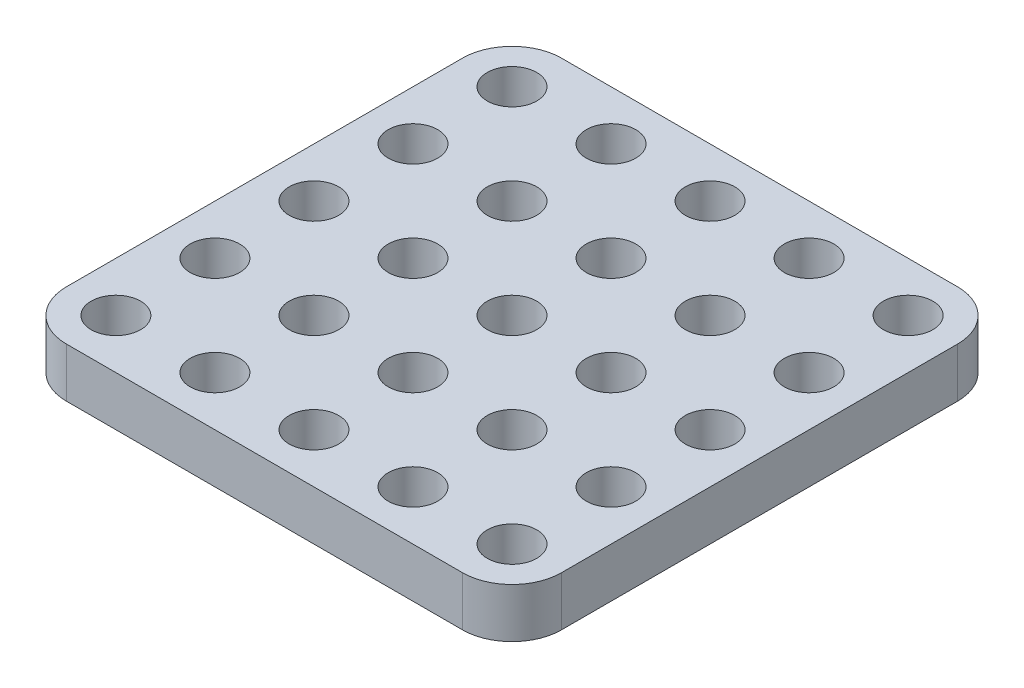
from build123d import *

# Parameters (mm, degrees)
SKETCH1_R           = 2.5
BOSS_EXTRUDE1_DEPTH = 5


with BuildPart() as part:
    # Sketch1 → Boss-Extrude1 (new body)
    with BuildSketch(Plane(origin=(0, 0, 0), x_dir=(1, 0, 0), z_dir=(0, 1, 0))):
        with BuildLine():
            Line((20, -25), (-20, -25))
            ThreePointArc((-20, -25), (-23.535533906, -23.535533906), (-25, -20))
            Line((-25, -20), (-25, 20))
            ThreePointArc((-25, 20), (-23.535533906, 23.535533906), (-20, 25))
            Line((-20, 25), (20, 25))
            ThreePointArc((20, 25), (23.535533906, 23.535533906), (25, 20))
            Line((25, 20), (25, -20))
            ThreePointArc((25, -20), (23.535533906, -23.535533906), (20, -25))
        make_face()
        with Locations((-20, 20)):
            Circle(SKETCH1_R, mode=Mode.SUBTRACT)
        with Locations((-10, 20)):
            Circle(SKETCH1_R, mode=Mode.SUBTRACT)
        with Locations((0, 20)):
            Circle(SKETCH1_R, mode=Mode.SUBTRACT)
        with Locations((10, 20)):
            Circle(SKETCH1_R, mode=Mode.SUBTRACT)
        with Locations((20, 20)):
            Circle(SKETCH1_R, mode=Mode.SUBTRACT)
        with Locations((-10, 10)):
            Circle(SKETCH1_R, mode=Mode.SUBTRACT)
        with Locations((0, 10)):
            Circle(SKETCH1_R, mode=Mode.SUBTRACT)
        with Locations((10, 10)):
            Circle(SKETCH1_R, mode=Mode.SUBTRACT)
        with Locations((20, 10)):
            Circle(SKETCH1_R, mode=Mode.SUBTRACT)
        with Locations((-10, 0)):
            Circle(SKETCH1_R, mode=Mode.SUBTRACT)
        Circle(SKETCH1_R, mode=Mode.SUBTRACT)
        with Locations((10, 0)):
            Circle(SKETCH1_R, mode=Mode.SUBTRACT)
        with Locations((20, 0)):
            Circle(SKETCH1_R, mode=Mode.SUBTRACT)
        with Locations((-10, -10)):
            Circle(SKETCH1_R, mode=Mode.SUBTRACT)
        with Locations((0, -10)):
            Circle(SKETCH1_R, mode=Mode.SUBTRACT)
        with Locations((10, -10)):
            Circle(SKETCH1_R, mode=Mode.SUBTRACT)
        with Locations((20, -10)):
            Circle(SKETCH1_R, mode=Mode.SUBTRACT)
        with Locations((-10, -20)):
            Circle(SKETCH1_R, mode=Mode.SUBTRACT)
        with Locations((0, -20)):
            Circle(SKETCH1_R, mode=Mode.SUBTRACT)
        with Locations((10, -20)):
            Circle(SKETCH1_R, mode=Mode.SUBTRACT)
        with Locations((20, -20)):
            Circle(SKETCH1_R, mode=Mode.SUBTRACT)
        with Locations((-20, 10)):
            Circle(SKETCH1_R, mode=Mode.SUBTRACT)
        with Locations((-20, 0)):
            Circle(SKETCH1_R, mode=Mode.SUBTRACT)
        with Locations((-20, -10)):
            Circle(SKETCH1_R, mode=Mode.SUBTRACT)
        with Locations((-20, -20)):
            Circle(SKETCH1_R, mode=Mode.SUBTRACT)
    extrude(amount=BOSS_EXTRUDE1_DEPTH)


solid = part.part
